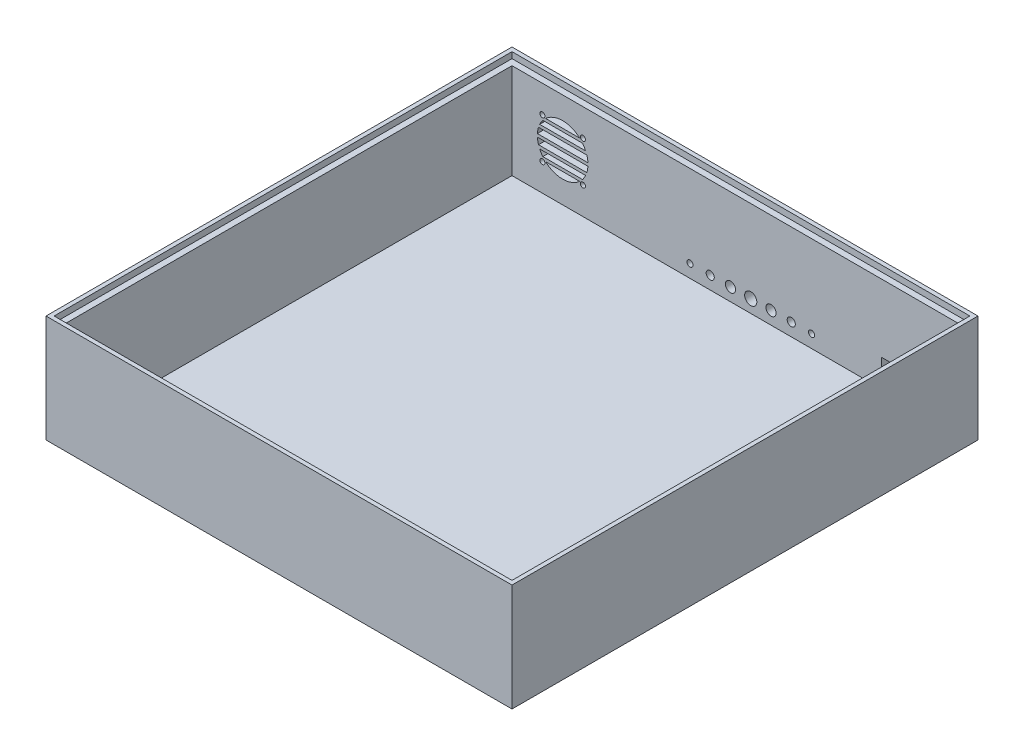
from build123d import *

# Parameters (mm, degrees)
ESQUISSE1_W             = 230
ESQUISSE1_H             = 230
BOSS_EXTRU_1_DEPTH      = 53
ESQUISSE2_W             = 220
ESQUISSE2_H             = 220
ENL_V_MAT_EXTRU_1_DEPTH = 50
ESQUISSE3_W             = 226
ESQUISSE3_H             = 226
ENL_V_MAT_EXTRU_2_DEPTH = 3
ESQUISSE4_R             = 12.5
ENL_V_MAT_EXTRU_3_DEPTH = 13
ESQUISSE5_R             = 1.25
ENL_V_MAT_EXTRU_4_DEPTH = 13
ESQUISSE6_W             = 26.976344154
ESQUISSE6_H             = 1.5
ESQUISSE6_W_2           = 27.280131813
ESQUISSE6_W_3           = 27.280131814
BOSS_EXTRU_2_DEPTH      = 5
ESQUISSE7_R             = 3
ENL_V_MAT_EXTRU_5_DEPTH = 5
ESQUISSE9_W             = 12.6
ESQUISSE9_H             = 11.4
ENL_V_MAT_EXTRU_6_DEPTH = 5
ESQUISSE10_R            = 1.5
ESQUISSE10_R_2          = 2
ESQUISSE10_R_3          = 2.5
ESQUISSE10_R_4          = 3
ENL_V_MAT_EXTRU_7_DEPTH = 10


with BuildPart() as part:
    # Esquisse1 → Boss.-Extru.1 (new body)
    with BuildSketch(Plane(origin=(0, 0, 0), x_dir=(1, 0, 0), z_dir=(0, 1, 0))):
        with Locations((115, 115)):
            Rectangle(ESQUISSE1_W, ESQUISSE1_H)
    extrude(amount=BOSS_EXTRU_1_DEPTH)

    # Esquisse2 → Enlèv. mat.-Extru.1 (cut)
    with BuildSketch(Plane(origin=(0, 53, 0), x_dir=(1, 0, 0), z_dir=(0, 1, 0))):
        with Locations((115, 115)):
            Rectangle(ESQUISSE2_W, ESQUISSE2_H)
    extrude(amount=-ENL_V_MAT_EXTRU_1_DEPTH, mode=Mode.SUBTRACT)

    # Esquisse3 → Enlèv. mat.-Extru.2 (cut)
    with BuildSketch(Plane(origin=(0, 53, 0), x_dir=(1, 0, 0), z_dir=(0, 1, 0))):
        with Locations((115, 115)):
            Rectangle(ESQUISSE3_W, ESQUISSE3_H)
    extrude(amount=-ENL_V_MAT_EXTRU_2_DEPTH, mode=Mode.SUBTRACT)

    # Esquisse4 → Enlèv. mat.-Extru.3 (cut)
    with BuildSketch(Plane(origin=(0, 0, -230), x_dir=(-1, 0, 0), z_dir=(0, 0, -1))):
        with Locations((-30, 26.5)):
            Circle(ESQUISSE4_R)
    extrude(amount=-ENL_V_MAT_EXTRU_3_DEPTH, mode=Mode.SUBTRACT)

    # Esquisse5 → Enlèv. mat.-Extru.4 (cut)
    with BuildSketch(Plane(origin=(0, 0, -230), x_dir=(-1, 0, 0), z_dir=(0, 0, -1))):
        with Locations((-40, 36.5)):
            Circle(ESQUISSE5_R)
        with Locations((-20, 36.5)):
            Circle(ESQUISSE5_R)
        with Locations((-20, 16.5)):
            Circle(ESQUISSE5_R)
        with Locations((-40, 16.5)):
            Circle(ESQUISSE5_R)
    extrude(amount=-ENL_V_MAT_EXTRU_4_DEPTH, mode=Mode.SUBTRACT)

    # Esquisse6 → Boss.-Extru.2 (add)
    with BuildSketch(Plane(origin=(0, 0, -230), x_dir=(-1, 0, 0), z_dir=(0, 0, -1))):
        with Locations((-29.668195525, 26.5)):
            Rectangle(ESQUISSE6_W, ESQUISSE6_H)
        with Locations((-29.516301696, 31)):
            Rectangle(ESQUISSE6_W_2, ESQUISSE6_H)
        with BuildLine():
            Line((-39.807522623, 18.75), (-20.192477377, 18.75))
            add(Edge.make_bspline(
                [(-20.192477377, 18.75), (-20.3726905, 17.550508754), (-21.59241414, 17.25)],
                knots=[0, 0, 0, 1, 1, 1], degree=2))
            Line((-21.59241414, 17.25), (-38.40758586, 17.25))
            add(Edge.make_bspline(
                [(-39.807522623, 18.75), (-39.455191276, 17.680066298), (-38.40758586, 17.25)],
                knots=[0, 0, 0, 1, 1, 1], degree=2))
        make_face()
        with Locations((-29.303650334, 22)):
            Rectangle(ESQUISSE6_W_3, ESQUISSE6_H)
        with BuildLine():
            Line((-39.807522623, 34.25), (-20.192477377, 34.25))
            add(Edge.make_bspline(
                [(-21.59241414, 35.75), (-20.476912109, 35.349681649), (-20.192477377, 34.25)],
                knots=[0, 0, 0, 1, 1, 1], degree=2))
            Line((-21.59241414, 35.75), (-38.40758586, 35.75))
            add(Edge.make_bspline(
                [(-39.807522623, 34.25), (-39.526090214, 35.47410851), (-38.40758586, 35.75)],
                knots=[0, 0, 0, 1, 1, 1], degree=2))
        make_face()
    extrude(amount=-BOSS_EXTRU_2_DEPTH)

    # Esquisse7 → Enlèv. mat.-Extru.5 (cut)
    with BuildSketch(Plane(origin=(0, 0, -230), x_dir=(-1, 0, 0), z_dir=(0, 0, -1))):
        with Locations((-215, 8)):
            Circle(ESQUISSE7_R)
    extrude(amount=-ENL_V_MAT_EXTRU_5_DEPTH, mode=Mode.SUBTRACT)

    # Esquisse9 → Enlèv. mat.-Extru.6 (cut)
    with BuildSketch(Plane(origin=(0, 0, -230), x_dir=(-1, 0, 0), z_dir=(0, 0, -1))):
        with Locations((-193.7, 10.836521705)):
            Rectangle(ESQUISSE9_W, ESQUISSE9_H)
    extrude(amount=-ENL_V_MAT_EXTRU_6_DEPTH, mode=Mode.SUBTRACT)

    # Esquisse10 → Enlèv. mat.-Extru.7 (cut)
    with BuildSketch(Plane(origin=(0, 0, -230), x_dir=(-1, 0, 0), z_dir=(0, 0, -1))):
        with Locations((-152.831654842, 9.359863556)):
            Circle(ESQUISSE10_R)
        with Locations((-142.831654842, 9.359863556)):
            Circle(ESQUISSE10_R_2)
        with Locations((-132.831654842, 9.359863556)):
            Circle(ESQUISSE10_R_3)
        with Locations((-122.831654842, 9.359863556)):
            Circle(ESQUISSE10_R_4)
        with Locations((-112.831654842, 9.359863556)):
            Circle(ESQUISSE10_R_3)
        with Locations((-102.831654842, 9.359863556)):
            Circle(ESQUISSE10_R_2)
        with Locations((-92.831654842, 9.359863556)):
            Circle(ESQUISSE10_R)
    extrude(amount=-ENL_V_MAT_EXTRU_7_DEPTH, mode=Mode.SUBTRACT)


solid = part.part
